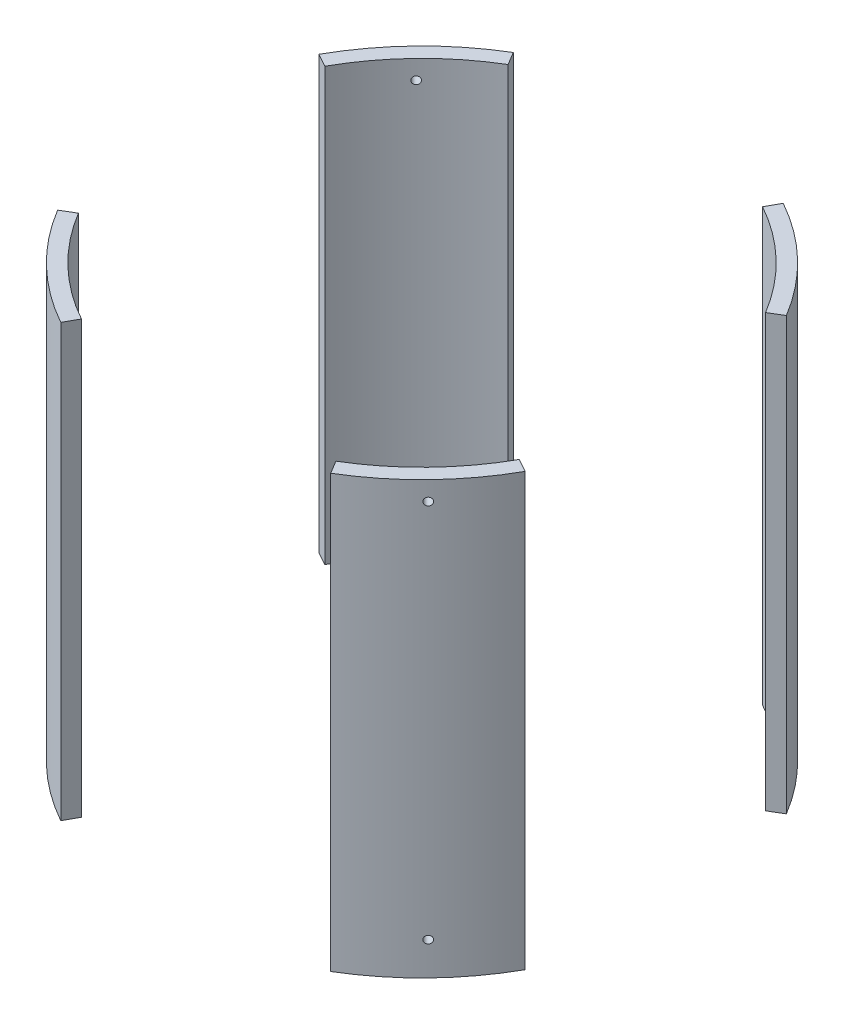
from build123d import *

# Parameters (mm, degrees)
SKETCH2_R               = 88.9
SKETCH2_R_2             = 83.82
BOSS_EXTRUDE1_DEPTH     = 72.22236
CUT_EXTRUDE1_DEPTH      = 73.22236
CUT_EXTRUDE1_DEPTH_BACK = 73.22236
SKETCH5_R               = 1.27
BOLT_HOLES_DEPTH        = 29.911624556
BOLT_PATTERN_COUNT      = 4


with BuildPart() as part:
    # Sketch2 → Boss-Extrude1 (new body, symmetric)
    with BuildSketch(Plane(origin=(0, 0, 0), x_dir=(1, 0, 0), z_dir=(0, 1, 0))):
        Circle(SKETCH2_R)
        Circle(SKETCH2_R_2, mode=Mode.SUBTRACT)
    extrude(amount=BOSS_EXTRUDE1_DEPTH, both=True)

    # Sketch3 → Cut-Extrude1 (cut, two sides)
    with BuildSketch(Plane(origin=(0, 0, 0), x_dir=(1, 0, 0), z_dir=(0, 1, 0))) as cut_extrude1_sk:
        Polygon((169.661755759, -94.300371224), (0, 0), (169.661755759, 101.677593364), align=None)
        Polygon((0, 0), (53.900027233, 96.974944394), (-58.116685864, 96.974944394), align=None)
        Polygon((-123.741299607, 68.777140945), (-123.741299607, -74.157652604), (0, 0), align=None)
        Polygon((-65.840936026, -118.45858783), (0, 0), (70.991745134, -118.45858783), align=None)
    extrude(amount=CUT_EXTRUDE1_DEPTH, mode=Mode.SUBTRACT)
    extrude(cut_extrude1_sk.sketch, amount=-CUT_EXTRUDE1_DEPTH_BACK, mode=Mode.SUBTRACT)

    # Sketch5 → Bolt holes (cut, through all)
    with BuildSketch(Plane(origin=(-56.309218645, 0, 58.175814955), x_dir=(-0.718540152, 0, -0.695485478), z_dir=(0.695485478, 0, -0.718540152))):
        with Locations((-0.02278764, 65.87236)):
            Circle(SKETCH5_R)
        with Locations((-0.02278764, -61.10986)):
            Circle(SKETCH5_R)
    bolt_holes = extrude(amount=-BOLT_HOLES_DEPTH, mode=Mode.SUBTRACT)

    # Bolt pattern: Bolt holes ×4 about axis
    bolt_pattern_axis = Axis((0, 72.22236, 0), (0, 1, 0))
    for i in range(1, BOLT_PATTERN_COUNT):
        add(bolt_holes.rotate(bolt_pattern_axis, i * 360 / BOLT_PATTERN_COUNT), mode=Mode.SUBTRACT)


solid = part.part
